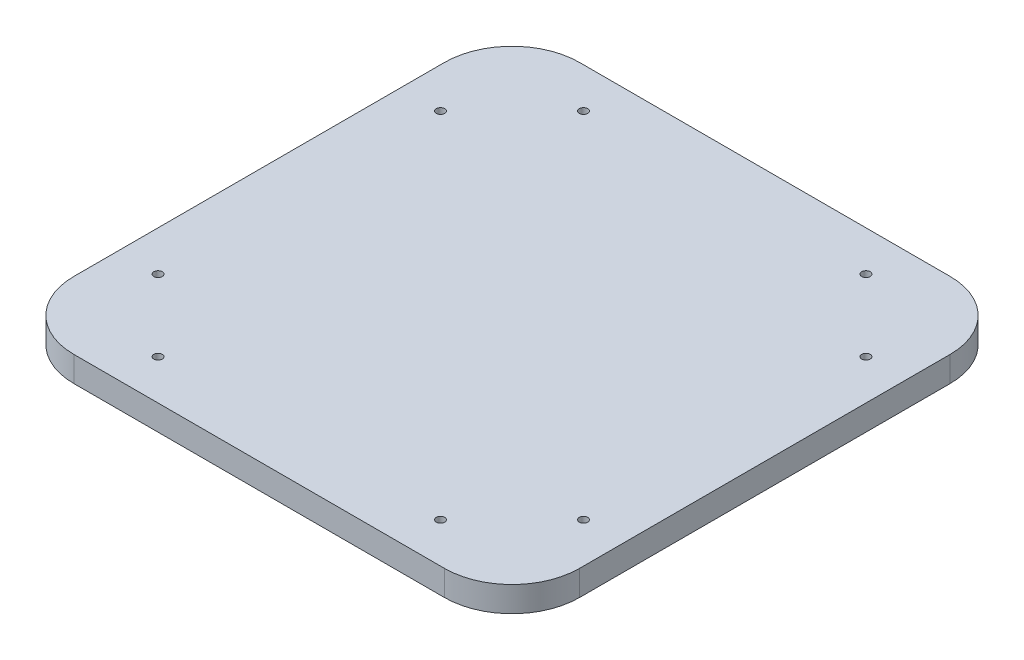
from build123d import *

# Parameters (mm, degrees)
SKETCH1_W           = 300
SKETCH1_H           = 300
BOSS_EXTRUDE1_DEPTH = 15
SKETCH3_R           = 2.5
CUT_EXTRUDE1_DEPTH  = 16
FILLET1_R           = 40


with BuildPart() as part:
    # Sketch1 → Boss-Extrude1 (new body)
    with BuildSketch(Plane(origin=(0, 0, 0), x_dir=(1, 0, 0), z_dir=(0, 1, 0))):
        Rectangle(SKETCH1_W, SKETCH1_H)
    extrude(amount=BOSS_EXTRUDE1_DEPTH)

    # Sketch3 → Cut-Extrude1 (cut, through all)
    with BuildSketch(Plane(origin=(0, 15, 0), x_dir=(1, 0, 0), z_dir=(0, 1, 0))):
        with Locations((-83.786796564, 126.213203436)):
            Circle(SKETCH3_R)
        with Locations((-126.213203436, 83.786796564)):
            Circle(SKETCH3_R)
        with Locations((126.213203436, 83.786796564)):
            Circle(SKETCH3_R)
        with Locations((83.786796564, 126.213203436)):
            Circle(SKETCH3_R)
        with Locations((83.786796564, -126.213203436)):
            Circle(SKETCH3_R)
        with Locations((126.213203436, -83.786796564)):
            Circle(SKETCH3_R)
        with Locations((-126.213203436, -83.786796564)):
            Circle(SKETCH3_R)
        with Locations((-83.786796564, -126.213203436)):
            Circle(SKETCH3_R)
    extrude(amount=-CUT_EXTRUDE1_DEPTH, mode=Mode.SUBTRACT)

    # Fillet1
    fillet1_edges = [part.edges().sort_by_distance(p)[0] for p in [
        (150, 7.5, 150),
        (-150, 7.5, 150),
        (-150, 7.5, -150),
        (150, 7.5, -150),
    ]]
    fillet(fillet1_edges, radius=FILLET1_R)


solid = part.part
